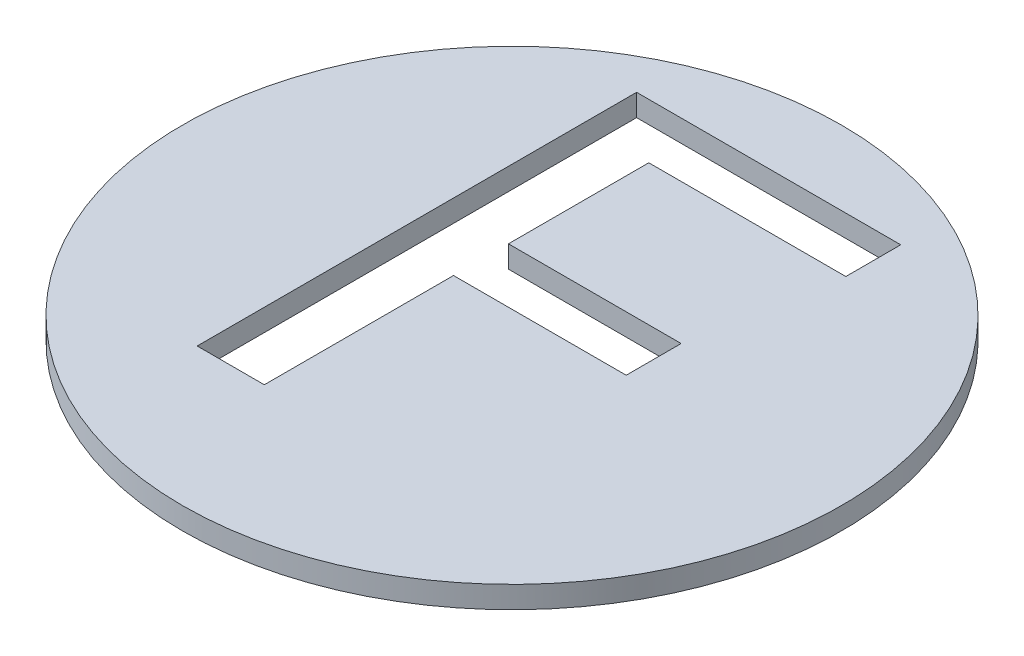
from build123d import *

# Parameters (mm, degrees)
SKETCH1_R           = 45
BOSS_EXTRUDE1_DEPTH = 3


with BuildPart() as part:
    # Sketch1 → Boss-Extrude1 (new body)
    with BuildSketch(Plane(origin=(0, 0, 0), x_dir=(1, 0, 0), z_dir=(0, 1, 0))):
        with Locations(Location((0, 0, 0), (0, 0, 270))):  # turned: the seam where the file's is
            Circle(SKETCH1_R)
        Polygon((18.201594334, 34.879867703), (18.201594334, 27.379867703), (-8.699447333, 27.379867703), (-8.699447333, 8.213201037), (14.881281834, 8.213201037), (14.881281834, 0.713201037), (-8.699447333, 0.713201037), (-8.699447333, -25.120132297), (-17.866113999, -25.120132297), (-17.866113999, 34.879867703), align=None, mode=Mode.SUBTRACT)
    extrude(amount=BOSS_EXTRUDE1_DEPTH)


solid = part.part
